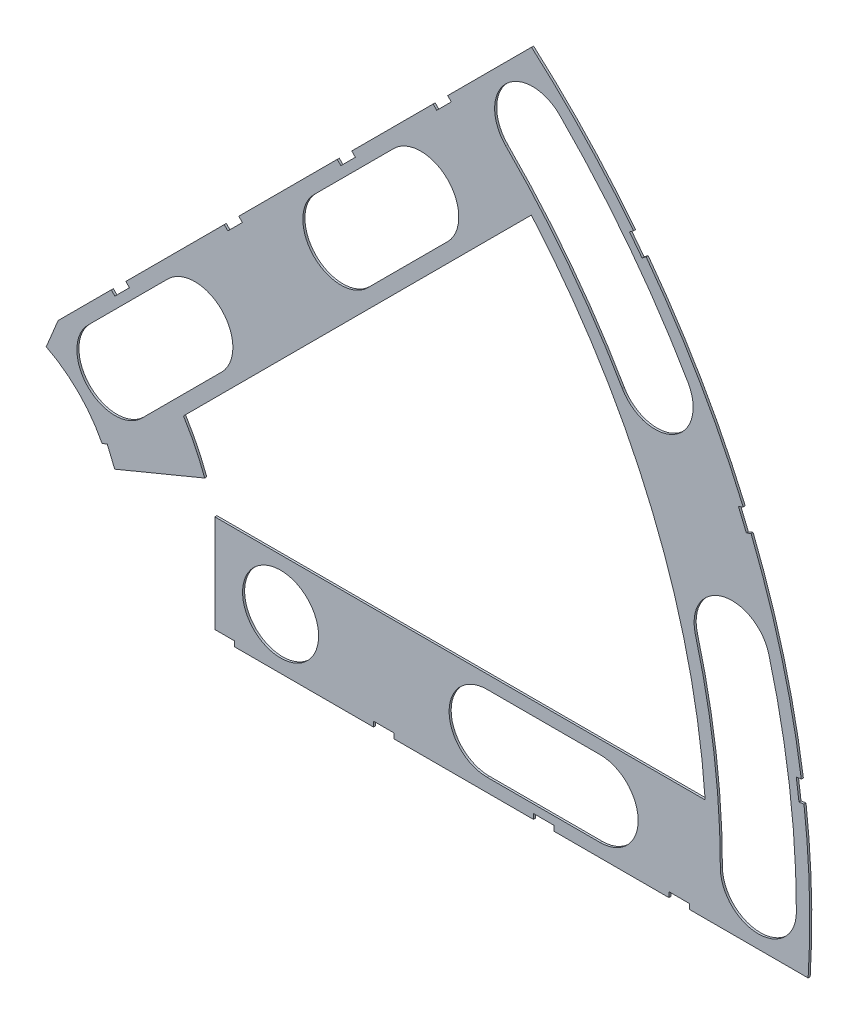
from build123d import *

# Parameters (mm, degrees)
BOSS_EXTRUDE1_DEPTH = 0.254
SKETCH2_R           = 4.699
CUT_EXTRUDE1_DEPTH  = 1.254
SKETCH3_W           = 2.54
SKETCH3_H           = 0.635
CUT_EXTRUDE2_DEPTH  = 1.254
CUT_EXTRUDE4_DEPTH  = 1.254
CUT_EXTRUDE5_DEPTH  = 1.254


with BuildPart() as part:
    # Sketch1 → Boss-Extrude1 (new body)
    with BuildSketch(Plane.XY):
        with BuildLine():
            Line((67.21146711, 76.191723231), (8.696654013, 17.676910134))
            Line((8.696654013, 17.676910134), (7.228954972, 14.133571205))
            ThreePointArc((7.228954972, 14.133571205), (14.666587579, 6.075099489), (15.105587123, -4.88230096))
            Line((15.105587123, -4.88230096), (18.648926052, -6.35))
            Line((18.648926052, -6.35), (101.401368334, -6.35))
            ThreePointArc((101.401368334, -6.35), (93.866160503, 38.880636728), (67.21146711, 76.191723231))
        make_face()
        with BuildLine():
            Line((88.672924278, 6.35), (27.86051193, 6.35))
            ThreePointArc((27.86051193, 6.35), (26.399857642, 10.93517908), (24.190484974, 15.210228852))
            Line((24.190484974, 15.210228852), (67.191354125, 58.211098004))
            ThreePointArc((67.191354125, 58.211098004), (82.13289044, 34.020557137), (88.672924278, 6.35))
        make_face(mode=Mode.SUBTRACT)
    extrude(amount=BOSS_EXTRUDE1_DEPTH)

    # Sketch2 → Cut-Extrude1 (cut, through all)
    with BuildSketch(Plane.XY.offset(0.254)):
        with Locations((22.225, 0)):
            Circle(SKETCH2_R)
        with Locations((36.195, 0)):
            Circle(SKETCH2_R)
        with Locations((61.722, 0)):
            Circle(SKETCH2_R)
        with Locations((75.692, 0)):
            Circle(SKETCH2_R)
        with Locations((95.25, 0)):
            Circle(SKETCH2_R)
        with Locations((15.715448212, 15.715448212)):
            Circle(SKETCH2_R)
        with Locations((25.593729945, 25.593729945)):
            Circle(SKETCH2_R)
        with Locations((43.644044748, 43.644044748)):
            Circle(SKETCH2_R)
        with Locations((53.522326482, 53.522326482)):
            Circle(SKETCH2_R)
        with Locations((92.004434954, 24.652514046)):
            Circle(SKETCH2_R)
        with Locations((82.48891971, 47.625)):
            Circle(SKETCH2_R)
        with Locations((67.351920908, 67.351920908)):
            Circle(SKETCH2_R)
    extrude(amount=-CUT_EXTRUDE1_DEPTH, mode=Mode.SUBTRACT)

    # Sketch3 → Cut-Extrude2 (cut, through all)
    with BuildSketch(Plane.XY.offset(0.254)):
        Polygon((15.266435406, 24.246691527), (17.06248663, 26.042742751), (17.511499436, 25.593729945), (15.715448212, 23.797678721), align=None)
        Polygon((44.991083167, 53.971339288), (43.195031942, 52.175288063), (43.644044748, 51.726275257), (45.440095973, 53.522326482), align=None)
        with Locations((29.21, -6.0325)):
            Rectangle(SKETCH3_W, SKETCH3_H)
        with Locations((68.707, -6.0325)):
            Rectangle(SKETCH3_W, SKETCH3_H)
        Polygon((29.230733674, 38.210989795), (31.026784898, 40.007041019), (31.475797704, 39.558028213), (29.67974648, 37.761976989), align=None)
        Polygon((56.845021246, 65.825277367), (55.048970022, 64.029226143), (55.497982828, 63.580213337), (57.294034052, 65.376264561), align=None)
        with Locations((48.9585, -6.0325)):
            Rectangle(SKETCH3_W, SKETCH3_H)
        with Locations((85.471, -6.0325)):
            Rectangle(SKETCH3_W, SKETCH3_H)
        Polygon((99.935462164, 14.437711971), (100.266998693, 11.919442024), (101.526133667, 12.085210288), (101.194597138, 14.603480236), align=None)
        Polygon((93.765504959, 37.464305742), (94.938831965, 37.950313702), (93.966816047, 40.296967714), (92.793489041, 39.810959755), align=None)
        Polygon((79.327792988, 62.471156422), (80.874047017, 60.456038938), (81.88160576, 61.229165953), (80.33535173, 63.244283437), align=None)
        Polygon((13.593916116, 7.005422516), (14.565932035, 4.658768503), (15.739259041, 5.144776462), (14.767243123, 7.491430475), align=None)
    extrude(amount=-CUT_EXTRUDE2_DEPTH, mode=Mode.SUBTRACT)

    # Sketch6 → Cut-Extrude4 (cut, through all)
    with BuildSketch(Plane.XY.offset(0.254)):
        with BuildLine():
            Line((12.392753447, 19.038142977), (22.27103518, 28.91642471))
            ThreePointArc((22.27103518, 28.91642471), (28.91642471, 28.91642471), (28.91642471, 22.27103518))
            Line((28.91642471, 22.27103518), (19.038142977, 12.392753447))
            ThreePointArc((19.038142977, 12.392753447), (12.392753447, 12.392753447), (12.392753447, 19.038142977))
        make_face()
        with BuildLine():
            Line((40.321349984, 46.966739513), (50.199631717, 56.845021246))
            ThreePointArc((50.199631717, 56.845021246), (56.845021246, 56.845021246), (56.845021246, 50.199631717))
            Line((56.845021246, 50.199631717), (46.966739513, 40.321349984))
            ThreePointArc((46.966739513, 40.321349984), (40.321349984, 40.321349984), (40.321349984, 46.966739513))
        make_face()
        with BuildLine():
            Line((61.722, 4.699), (75.692, 4.699))
            ThreePointArc((75.692, 4.699), (80.391, 0), (75.692, -4.699))
            Line((75.692, -4.699), (61.722, -4.699))
            ThreePointArc((61.722, -4.699), (57.023, 0), (61.722, 4.699))
        make_face()
        with BuildLine():
            ThreePointArc((99.949, 0), (99.093922449, 13.045962386), (96.543320412, 25.868704739))
            ThreePointArc((96.543320412, 25.868704739), (90.788244261, 29.191399504), (87.465549496, 23.436323353))
            ThreePointArc((87.465549496, 23.436323353), (89.776323642, 11.819277232), (90.551, 0))
            ThreePointArc((90.551, 0), (95.25, -4.699), (99.949, 0))
        make_face()
        with BuildLine():
            ThreePointArc((86.558373083, 49.9745), (79.294873009, 60.845096068), (70.674615673, 70.674615673))
            ThreePointArc((70.674615673, 70.674615673), (64.029226143, 70.674615673), (64.029226143, 64.029226143))
            ThreePointArc((64.029226143, 64.029226143), (71.838938317, 55.123956158), (78.419466338, 45.2755))
            ThreePointArc((78.419466338, 45.2755), (84.83841971, 43.555546628), (86.558373083, 49.9745))
        make_face()
    extrude(amount=-CUT_EXTRUDE4_DEPTH, mode=Mode.SUBTRACT)

    # Sketch5 → Cut-Extrude5 (cut, through all)
    with BuildSketch(Plane.XY.offset(0.254)):
        Polygon((11.640421912, 3.584446343), (28.067, 10.38855777), (28.067, -7.62), (11.640421912, -7.62), align=None)
    extrude(amount=-CUT_EXTRUDE5_DEPTH, mode=Mode.SUBTRACT)


solid = part.part
